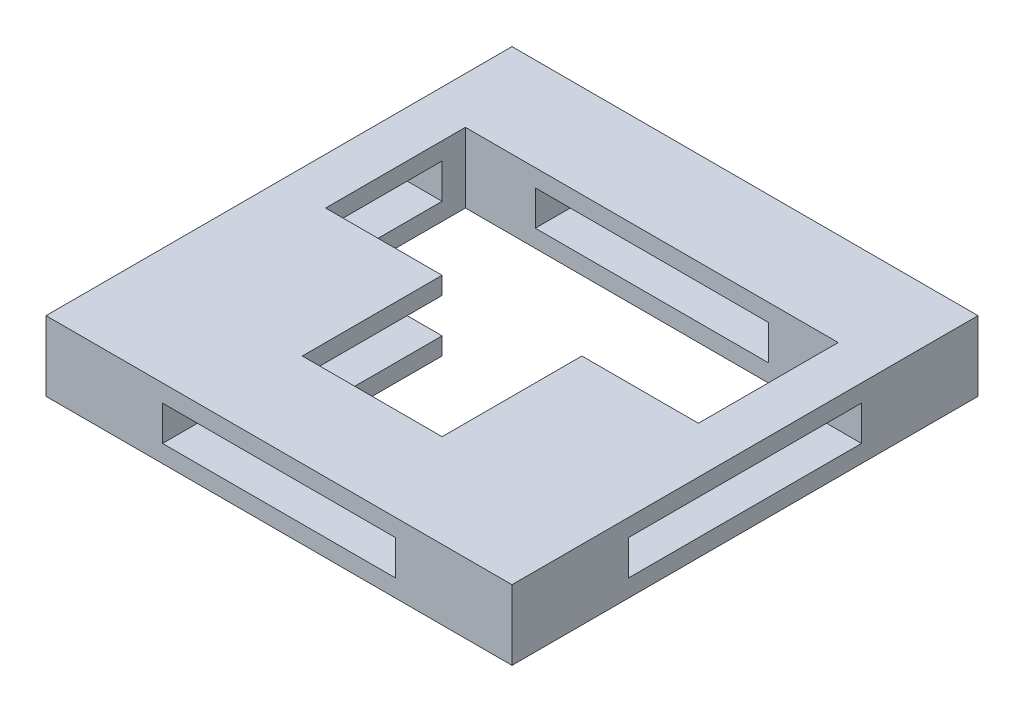
from build123d import *

# Parameters (mm, degrees)
SKETCH1_W           = 20
SKETCH1_H           = 20
BOSS_EXTRUDE1_DEPTH = 3
SKETCH2_W           = 10
SKETCH2_H           = 1.5
CUT_EXTRUDE1_DEPTH  = 21
SKETCH3_W           = 10
SKETCH3_H           = 1.5
CUT_EXTRUDE2_DEPTH  = 21


with BuildPart() as part:
    # Sketch1 → Boss-Extrude1 (new body)
    with BuildSketch(Plane(origin=(0, 0, 0), x_dir=(1, 0, 0), z_dir=(0, 1, 0))):
        Rectangle(SKETCH1_W, SKETCH1_H)
        Polygon((-3, 0), (-8, 0), (-8, 6), (8, 6), (8, 0), (3, 0), (3, -6), (-3, -6), align=None, mode=Mode.SUBTRACT)
    extrude(amount=BOSS_EXTRUDE1_DEPTH)

    # Sketch2 → Cut-Extrude1 (cut, through all)
    with BuildSketch(Plane.XY.offset(10)):
        with Locations((0, 1.5)):
            Rectangle(SKETCH2_W, SKETCH2_H)
    extrude(amount=-CUT_EXTRUDE1_DEPTH, mode=Mode.SUBTRACT)

    # Sketch3 → Cut-Extrude2 (cut, through all)
    with BuildSketch(Plane(origin=(10, 0, 0), x_dir=(0, 0, -1), z_dir=(1, 0, 0))):
        with Locations((0, 1.5)):
            Rectangle(SKETCH3_W, SKETCH3_H)
    extrude(amount=-CUT_EXTRUDE2_DEPTH, mode=Mode.SUBTRACT)


solid = part.part
